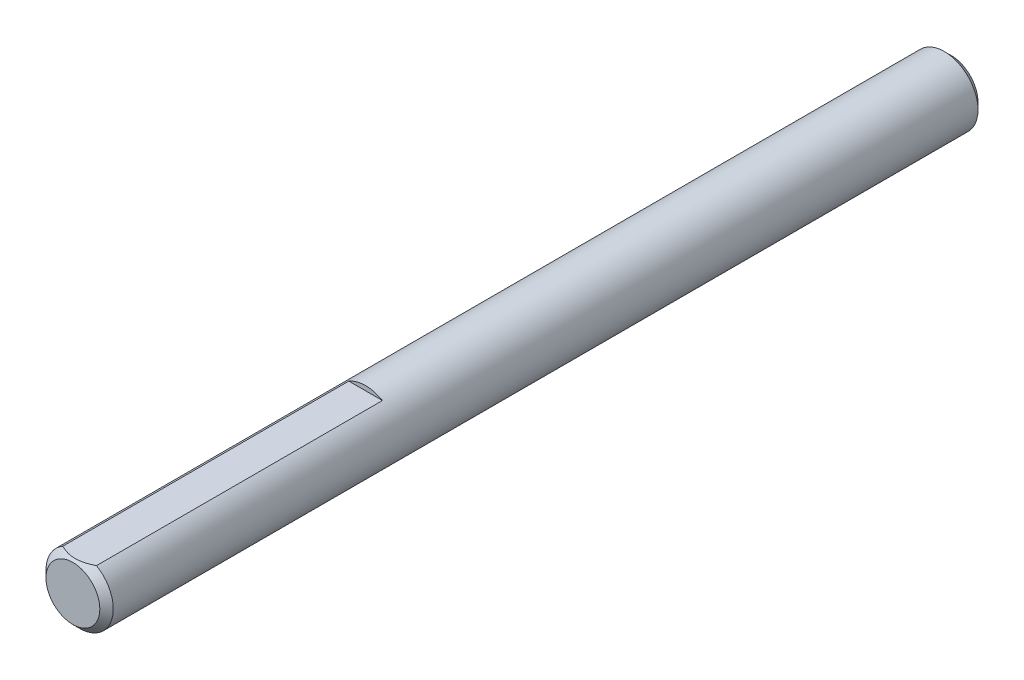
from build123d import *

# Parameters (mm, degrees)
SKETCH1_R      = 2.921
EXTRUDE1_DEPTH = 38.1
CHAMFER1_SIZE  = 0.5842
EXTRUDE7_DEPTH = 26.4


with BuildPart() as part:
    # Sketch1 → Extrude1 (new body, symmetric)
    with BuildSketch(Plane.XY):
        Circle(SKETCH1_R)
    extrude(amount=EXTRUDE1_DEPTH, both=True)

    # Chamfer1
    chamfer1_edges = [part.edges().sort_by_distance(p)[0] for p in [
        (-2.921, 0, -38.1),
        (-2.921, 0, 38.1),
    ]]
    chamfer(chamfer1_edges, length=CHAMFER1_SIZE)

    # Sketch13 → Extrude7 (cut, through all)
    with BuildSketch(Plane.XY.offset(12.7)):
        with BuildLine():
            Line((-1.4605, 2.529660204), (1.4605, 2.529660204))
            ThreePointArc((1.4605, 2.529660204), (0, 2.921), (-1.4605, 2.529660204))
        make_face()
    extrude(amount=EXTRUDE7_DEPTH, mode=Mode.SUBTRACT)


solid = part.part
